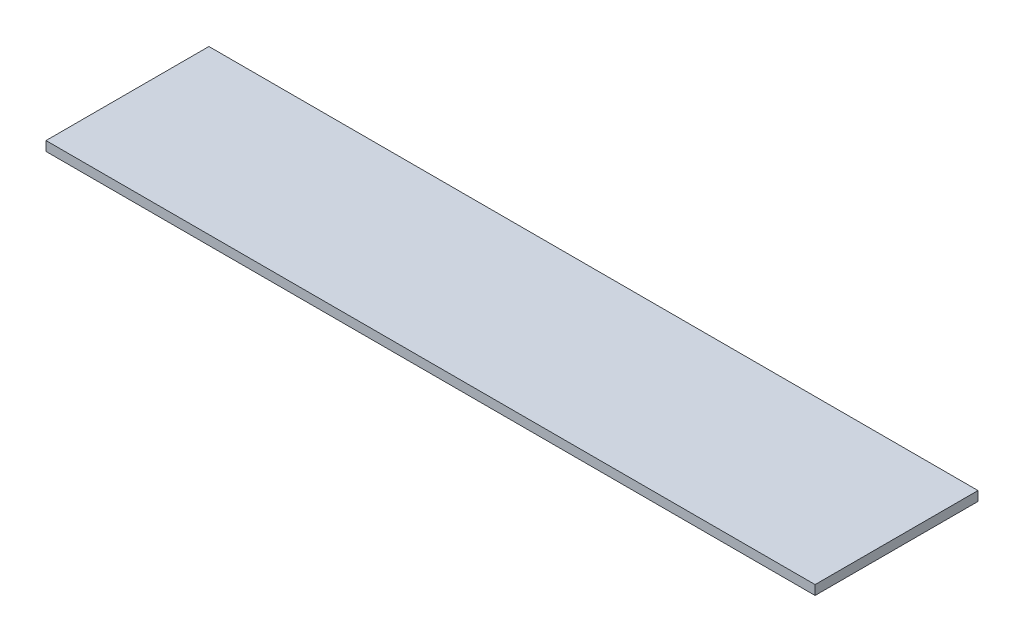
from build123d import *

# Parameters (mm, degrees)
SKETCH1_W           = 406
SKETCH1_H           = 86
BOSS_EXTRUDE1_DEPTH = 5


with BuildPart() as part:
    # Sketch1 → Boss-Extrude1 (new body)
    with BuildSketch(Plane(origin=(0, 0, 0), x_dir=(1, 0, 0), z_dir=(0, 1, 0))):
        Rectangle(SKETCH1_W, SKETCH1_H)
    extrude(amount=BOSS_EXTRUDE1_DEPTH)


solid = part.part
